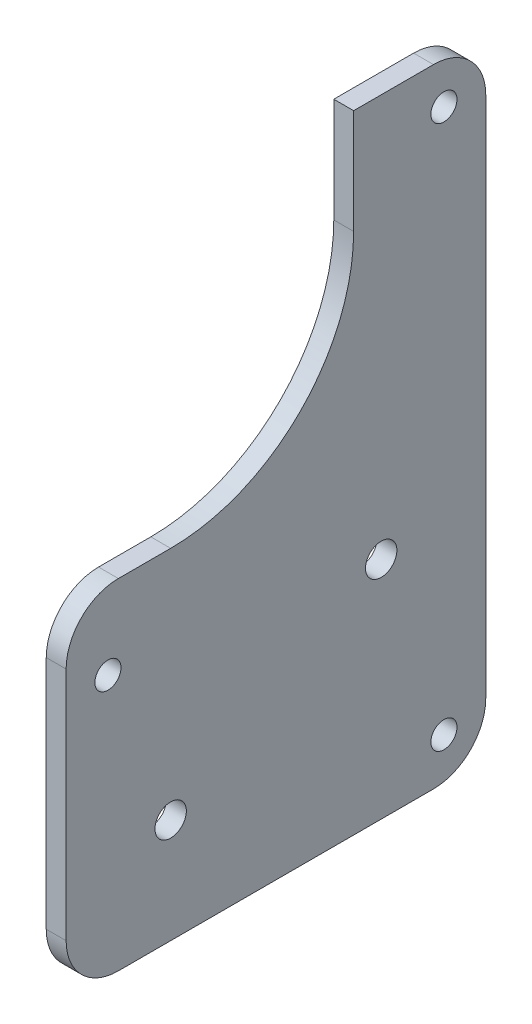
from build123d import *

# Parameters (mm, degrees)
SKETCH1_R           = 3
SKETCH1_R_2         = 2.5
BOSS_EXTRUDE1_DEPTH = 3.8
FILLET1_R           = 10


with BuildPart() as part:
    # Sketch1 → Boss-Extrude1 (new body)
    with BuildSketch(Plane(origin=(0, 0, 0), x_dir=(0, 0, -1), z_dir=(1, 0, 0))):
        with BuildLine():
            Line((-33.760087735, -70.625), (46.510087735, -70.625))
            Line((46.510087735, -70.625), (46.510087735, 49.375))
            Line((46.510087735, 49.375), (21.239912265, 49.375))
            Line((21.239912265, 49.375), (21.239912265, 29.375))
            ThreePointArc((21.239912265, 29.375), (10.988649606, 4.626262658), (-13.760087735, -5.625))
            Line((-13.760087735, -5.625), (-33.760087735, -5.625))
            Line((-33.760087735, -5.625), (-33.760087735, -70.625))
        make_face()
        with Locations((-13.760087735, -50.625)):
            Circle(SKETCH1_R, mode=Mode.SUBTRACT)
        with Locations((26.510087735, -27.575640625)):
            Circle(SKETCH1_R, mode=Mode.SUBTRACT)
        with Locations((38.510087735, 41.375)):
            Circle(SKETCH1_R_2, mode=Mode.SUBTRACT)
        with Locations((38.510087735, -62.625)):
            Circle(SKETCH1_R_2, mode=Mode.SUBTRACT)
        with Locations((-25.760087735, -20.625)):
            Circle(SKETCH1_R_2, mode=Mode.SUBTRACT)
    extrude(amount=BOSS_EXTRUDE1_DEPTH)

    # Fillet1
    fillet1_edges = [part.edges().sort_by_distance(p)[0] for p in [
        (1.9, -70.625, -46.510087735),
        (1.9, -70.625, 33.760087735),
        (1.9, -5.625, 33.760087735),
        (1.9, 49.375, -46.510087735),
    ]]
    fillet(fillet1_edges, radius=FILLET1_R)


solid = part.part
